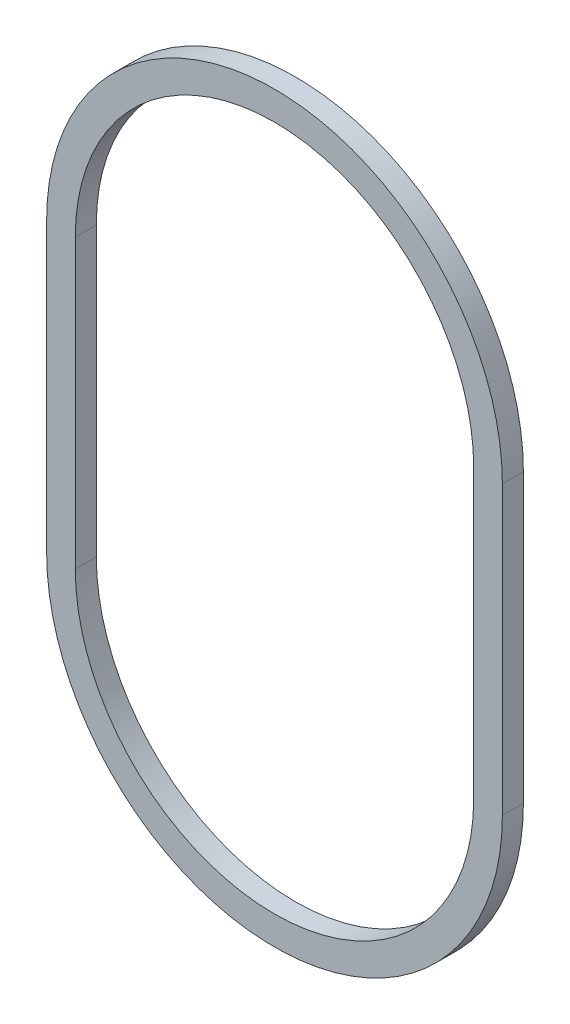
from build123d import *

# Parameters (mm, degrees)
BOSS_EXTRUDE1_DEPTH = 2.2


with BuildPart() as part:
    # Sketch1 → Boss-Extrude1 (new body)
    with BuildSketch(Plane.XY):
        with BuildLine():
            Line((-23.85, 15.04), (-23.85, -15.04))
            ThreePointArc((-23.85, -15.04), (0, -38.89), (23.85, -15.04))
            Line((23.85, -15.04), (23.85, 15.04))
            ThreePointArc((23.85, 15.04), (0, 38.89), (-23.85, 15.04))
        make_face()
        with BuildLine():
            Line((-20.85, 15.04), (-20.85, -15.04))
            ThreePointArc((-20.85, -15.04), (0, -35.89), (20.85, -15.04))
            Line((20.85, -15.04), (20.85, 15.04))
            ThreePointArc((20.85, 15.04), (0, 35.89), (-20.85, 15.04))
        make_face(mode=Mode.SUBTRACT)
    extrude(amount=BOSS_EXTRUDE1_DEPTH)


solid = part.part
